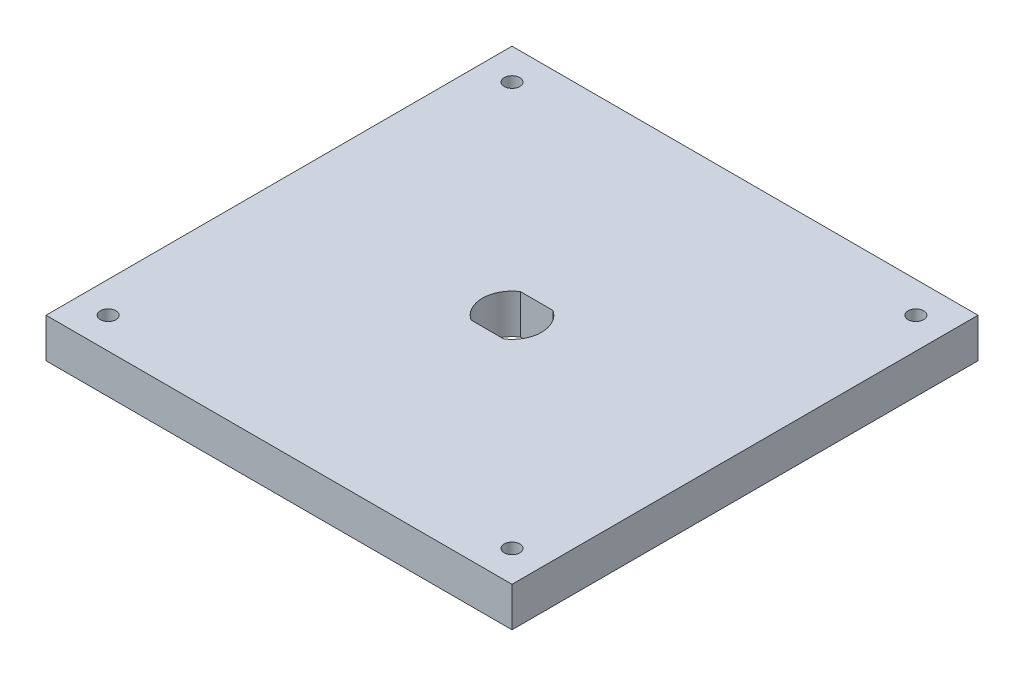
from build123d import *

# Parameters (mm, degrees)
SKETCH1_W           = 150
SKETCH1_H           = 150
BOSS_EXTRUDE1_DEPTH = 12.7
SKETCH2_W           = 10.53028371
SKETCH2_H           = 7.9375
SKETCH2_R           = 2.5
CUT_EXTRUDE1_DEPTH  = 12.7


with BuildPart() as part:
    # Sketch1 → Boss-Extrude1 (new body)
    with BuildSketch(Plane(origin=(0, 0, 0), x_dir=(1, 0, 0), z_dir=(0, 1, 0))):
        with Locations((75, 75)):
            Rectangle(SKETCH1_W, SKETCH1_H)
    extrude(amount=BOSS_EXTRUDE1_DEPTH)

    # Sketch2 → Cut-Extrude1 (cut)
    with BuildSketch(Plane(origin=(0, 12.7, 0), x_dir=(1, 0, 0), z_dir=(0, 1, 0))):
        with BuildLine():
            ThreePointArc((80.265141855, 67.0625), (83.392737967, 70.495827), (84.525, 75))
            Line((84.525, 75), (80.265141855, 75))
            Line((80.265141855, 75), (80.265141855, 67.0625))
        make_face()
        with BuildLine():
            Line((80.265141855, 75), (84.525, 75))
            ThreePointArc((84.525, 75), (83.392737967, 79.504173), (80.265141855, 82.9375))
            Line((80.265141855, 82.9375), (80.265141855, 75))
        make_face()
        with BuildLine():
            Line((69.734858145, 67.0625), (69.734858145, 75))
            Line((69.734858145, 75), (65.475, 75))
            ThreePointArc((65.475, 75), (66.607262033, 70.495827), (69.734858145, 67.0625))
        make_face()
        with BuildLine():
            Line((65.475, 75), (69.734858145, 75))
            Line((69.734858145, 75), (69.734858145, 82.9375))
            ThreePointArc((69.734858145, 82.9375), (66.607262033, 79.504173), (65.475, 75))
        make_face()
        with Locations((75, 78.96875)):
            Rectangle(SKETCH2_W, SKETCH2_H)
        with Locations((75, 71.03125)):
            Rectangle(SKETCH2_W, SKETCH2_H)
        with Locations((10, 140)):
            Circle(SKETCH2_R)
        with Locations((140, 140)):
            Circle(SKETCH2_R)
        with Locations((140, 10)):
            Circle(SKETCH2_R)
        with Locations((10, 10)):
            Circle(SKETCH2_R)
    extrude(amount=-CUT_EXTRUDE1_DEPTH, mode=Mode.SUBTRACT)


solid = part.part
